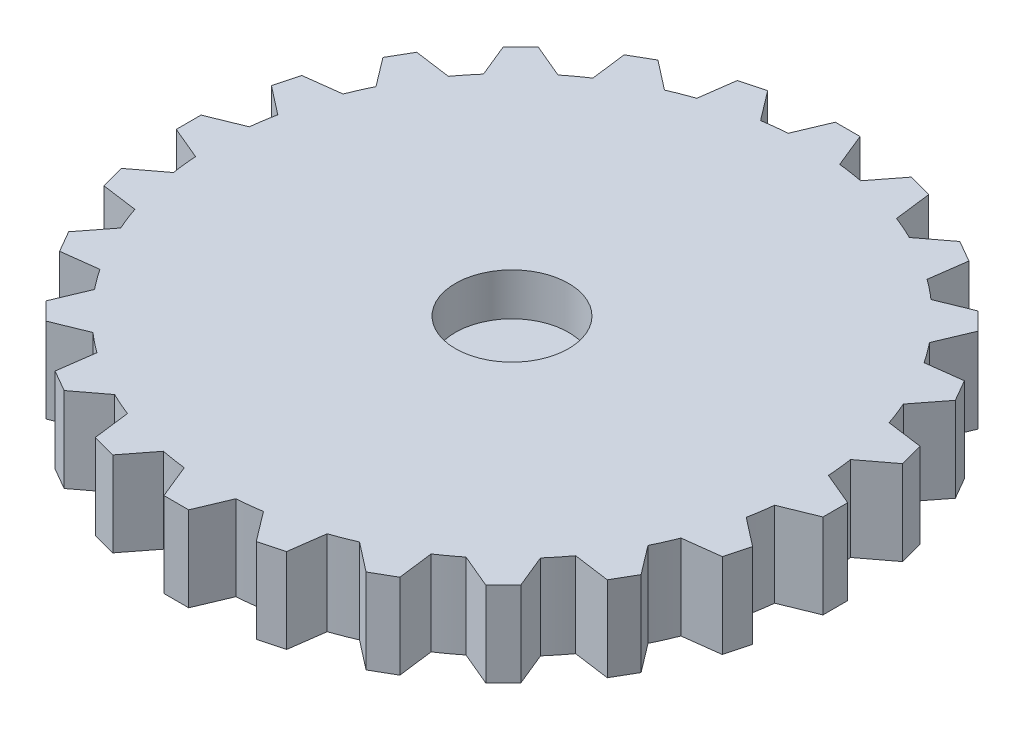
from build123d import *

# Parameters (mm, degrees)
BOSS_EXTRUDE5_DEPTH = 6
BOSS_EXTRUDE6_DEPTH = 3
SKETCH4_R           = 4
CUT_EXTRUDE1_DEPTH  = 10


with BuildPart() as part:
    # Sketch3 → Boss-Extrude5 (new body)
    with BuildSketch(Plane(origin=(0, 0, 0), x_dir=(1, 0, 0), z_dir=(0, 1, 0))):
        with BuildLine():
            Line((23.301465589, -1.311541929), (23.301465589, 0.438458071))
            Line((23.301465589, 0.438458071), (20.951465589, 1.426916143))
            ThreePointArc((20.951465589, 1.426916143), (20.873013262, 2.30593091), (20.757698449, 3.180873321))
            Line((20.757698449, 3.180873321), (22.846939432, 4.764010852))
            Line((22.846939432, 4.764010852), (22.394006103, 6.454381048))
            Line((22.394006103, 6.454381048), (19.868248637, 6.800933471))
            ThreePointArc((19.868248637, 6.800933471), (19.564963746, 7.629691581), (19.227126431, 8.444975382))
            Line((19.227126431, 8.444975382), (20.83543211, 10.514904166))
            Line((20.83543211, 10.514904166), (19.96043211, 12.030448623))
            Line((19.96043211, 12.030448623), (17.431043375, 11.711478423))
            ThreePointArc((17.431043375, 11.711478423), (16.923594283, 12.433501379), (16.386257521, 13.133566327))
            Line((16.386257521, 13.133566327), (17.404024521, 15.549224138))
            Line((17.404024521, 15.549224138), (16.166587654, 16.786661005))
            Line((16.166587654, 16.786661005), (13.805941313, 15.823905474))
            ThreePointArc((13.805941313, 15.823905474), (13.128909838, 16.389988605), (12.42869224, 16.927126431))
            Line((12.42869224, 16.927126431), (12.786561423, 19.523890181))
            Line((12.786561423, 19.523890181), (11.271016966, 20.398890181))
            Line((11.271016966, 20.398890181), (9.239987166, 18.857959518))
            ThreePointArc((9.239987166, 18.857959518), (8.439511883, 19.229525194), (7.624132122, 19.567130842))
            Line((7.624132122, 19.567130842), (7.297715294, 22.168035373))
            Line((7.297715294, 22.168035373), (5.607345098, 22.620968702))
            Line((5.607345098, 22.620968702), (4.044343163, 20.606874784))
            ThreePointArc((4.044343163, 20.606874784), (3.174975141, 20.758601419), (2.3, 20.873667622))
            Line((2.3, 20.873667622), (1.311541929, 23.301465589))
            Line((1.311541929, 23.301465589), (-0.438458071, 23.301465589))
            Line((-0.438458071, 23.301465589), (-1.426916143, 20.951465589))
            ThreePointArc((-1.426916143, 20.951465589), (-2.30593091, 20.873013262), (-3.180873321, 20.757698449))
            Line((-3.180873321, 20.757698449), (-4.764010852, 22.846939432))
            Line((-4.764010852, 22.846939432), (-6.454381048, 22.394006103))
            Line((-6.454381048, 22.394006103), (-6.800933471, 19.868248637))
            ThreePointArc((-6.800933471, 19.868248637), (-7.629691581, 19.564963746), (-8.444975382, 19.227126431))
            Line((-8.444975382, 19.227126431), (-10.514904166, 20.83543211))
            Line((-10.514904166, 20.83543211), (-12.030448623, 19.96043211))
            Line((-12.030448623, 19.96043211), (-11.711478423, 17.431043375))
            ThreePointArc((-11.711478423, 17.431043375), (-12.433501379, 16.923594283), (-13.133566327, 16.386257521))
            Line((-13.133566327, 16.386257521), (-15.549224138, 17.404024521))
            Line((-15.549224138, 17.404024521), (-16.786661005, 16.166587654))
            Line((-16.786661005, 16.166587654), (-15.823905474, 13.805941313))
            ThreePointArc((-15.823905474, 13.805941313), (-16.389988605, 13.128909838), (-16.927126431, 12.42869224))
            Line((-16.927126431, 12.42869224), (-19.523890181, 12.786561423))
            Line((-19.523890181, 12.786561423), (-20.398890181, 11.271016966))
            Line((-20.398890181, 11.271016966), (-18.857959518, 9.239987166))
            ThreePointArc((-18.857959518, 9.239987166), (-19.229525194, 8.439511883), (-19.567130842, 7.624132122))
            Line((-19.567130842, 7.624132122), (-22.168035373, 7.297715294))
            Line((-22.168035373, 7.297715294), (-22.620968702, 5.607345098))
            Line((-22.620968702, 5.607345098), (-20.606874784, 4.044343163))
            ThreePointArc((-20.606874784, 4.044343163), (-20.758601419, 3.174975141), (-20.873667622, 2.3))
            Line((-20.873667622, 2.3), (-23.301465589, 1.311541929))
            Line((-23.301465589, 1.311541929), (-23.301465589, -0.438458071))
            Line((-23.301465589, -0.438458071), (-20.951465589, -1.426916143))
            ThreePointArc((-20.951465589, -1.426916143), (-20.873013262, -2.30593091), (-20.757698449, -3.180873321))
            Line((-20.757698449, -3.180873321), (-22.846939432, -4.764010852))
            Line((-22.846939432, -4.764010852), (-22.394006103, -6.454381048))
            Line((-22.394006103, -6.454381048), (-19.868248637, -6.800933471))
            ThreePointArc((-19.868248637, -6.800933471), (-19.564963746, -7.629691581), (-19.227126431, -8.444975382))
            Line((-19.227126431, -8.444975382), (-20.83543211, -10.514904166))
            Line((-20.83543211, -10.514904166), (-19.96043211, -12.030448623))
            Line((-19.96043211, -12.030448623), (-17.431043375, -11.711478423))
            ThreePointArc((-17.431043375, -11.711478423), (-16.923594283, -12.433501379), (-16.386257521, -13.133566327))
            Line((-16.386257521, -13.133566327), (-17.404024521, -15.549224138))
            Line((-17.404024521, -15.549224138), (-16.166587654, -16.786661005))
            Line((-16.166587654, -16.786661005), (-13.805941313, -15.823905474))
            ThreePointArc((-13.805941313, -15.823905474), (-13.128909838, -16.389988605), (-12.42869224, -16.927126431))
            Line((-12.42869224, -16.927126431), (-12.786561423, -19.523890181))
            Line((-12.786561423, -19.523890181), (-11.271016966, -20.398890181))
            Line((-11.271016966, -20.398890181), (-9.239987166, -18.857959518))
            ThreePointArc((-9.239987166, -18.857959518), (-8.439511883, -19.229525194), (-7.624132122, -19.567130842))
            Line((-7.624132122, -19.567130842), (-7.297715294, -22.168035373))
            Line((-7.297715294, -22.168035373), (-5.607345098, -22.620968702))
            Line((-5.607345098, -22.620968702), (-4.044343163, -20.606874784))
            ThreePointArc((-4.044343163, -20.606874784), (-3.174975141, -20.758601419), (-2.3, -20.873667622))
            Line((-2.3, -20.873667622), (-1.311541929, -23.301465589))
            Line((-1.311541929, -23.301465589), (0.438458071, -23.301465589))
            Line((0.438458071, -23.301465589), (1.426916143, -20.951465589))
            ThreePointArc((1.426916143, -20.951465589), (2.30593091, -20.873013262), (3.180873321, -20.757698449))
            Line((3.180873321, -20.757698449), (4.764010852, -22.846939432))
            Line((4.764010852, -22.846939432), (6.454381048, -22.394006103))
            Line((6.454381048, -22.394006103), (6.800933471, -19.868248637))
            ThreePointArc((6.800933471, -19.868248637), (7.629691581, -19.564963746), (8.444975382, -19.227126431))
            Line((8.444975382, -19.227126431), (10.514904166, -20.83543211))
            Line((10.514904166, -20.83543211), (12.030448623, -19.96043211))
            Line((12.030448623, -19.96043211), (11.711478423, -17.431043375))
            ThreePointArc((11.711478423, -17.431043375), (12.433501379, -16.923594283), (13.133566327, -16.386257521))
            Line((13.133566327, -16.386257521), (15.549224138, -17.404024521))
            Line((15.549224138, -17.404024521), (16.786661005, -16.166587654))
            Line((16.786661005, -16.166587654), (15.823905474, -13.805941313))
            ThreePointArc((15.823905474, -13.805941313), (16.389988605, -13.128909838), (16.927126431, -12.42869224))
            Line((16.927126431, -12.42869224), (19.523890181, -12.786561423))
            Line((19.523890181, -12.786561423), (20.398890181, -11.271016966))
            Line((20.398890181, -11.271016966), (18.857959518, -9.239987166))
            ThreePointArc((18.857959518, -9.239987166), (19.229525194, -8.439511883), (19.567130842, -7.624132122))
            Line((19.567130842, -7.624132122), (22.168035373, -7.297715294))
            Line((22.168035373, -7.297715294), (22.620968702, -5.607345098))
            Line((22.620968702, -5.607345098), (20.606874784, -4.044343163))
            ThreePointArc((20.606874784, -4.044343163), (20.758601419, -3.174975141), (20.873667622, -2.3))
            Line((20.873667622, -2.3), (23.301465589, -1.311541929))
        make_face()
    extrude(amount=BOSS_EXTRUDE5_DEPTH)

    # Sketch4 → Cut-Extrude1 (cut)
    with BuildSketch(Plane(origin=(0, 6, 0), x_dir=(1, 0, 0), z_dir=(0, 1, 0))):
        Circle(SKETCH4_R)
    extrude(amount=-CUT_EXTRUDE1_DEPTH, mode=Mode.SUBTRACT)


with BuildPart() as body_2:
    # Sketch1 → Boss-Extrude6 (new body)
    with BuildSketch(Plane(origin=(0, 0, 0), x_dir=(1, 0, 0), z_dir=(0, 1, 0))):
        with BuildLine():
            Line((-0.5, 14.746169466), (0.5, 14.746169466))
            Line((0.5, 14.746169466), (2, 12.544128437))
            ThreePointArc((2, 12.544128437), (2.588190451, 12.405427729), (3.166928678, 12.23145084))
            Line((3.166928678, 12.23145084), (5.566987298, 13.388474311))
            Line((5.566987298, 13.388474311), (6.433012702, 12.888474311))
            Line((6.433012702, 12.888474311), (6.631030293, 10.23145084))
            ThreePointArc((6.631030293, 10.23145084), (7.071067812, 9.817237278), (7.485281374, 9.377199759))
            Line((7.485281374, 9.377199759), (10.142304845, 9.179182168))
            Line((10.142304845, 9.179182168), (10.642304845, 8.313156764))
            Line((10.642304845, 8.313156764), (9.485281374, 5.913098144))
            ThreePointArc((9.485281374, 5.913098144), (9.659258263, 5.334359917), (9.797958971, 4.746169466))
            Line((9.797958971, 4.746169466), (12, 3.246169466))
            Line((12, 3.246169466), (12, 2.246169466))
            Line((12, 2.246169466), (9.797958971, 0.746169466))
            ThreePointArc((9.797958971, 0.746169466), (9.659258263, 0.157979015), (9.485281374, -0.420759212))
            Line((9.485281374, -0.420759212), (10.642304845, -2.820817832))
            Line((10.642304845, -2.820817832), (10.142304845, -3.686843236))
            Line((10.142304845, -3.686843236), (7.485281374, -3.884860827))
            ThreePointArc((7.485281374, -3.884860827), (7.071067812, -4.324898346), (6.631030293, -4.739111908))
            Line((6.631030293, -4.739111908), (6.433012702, -7.39613538))
            Line((6.433012702, -7.39613538), (5.566987298, -7.89613538))
            Line((5.566987298, -7.89613538), (3.166928678, -6.739111908))
            ThreePointArc((3.166928678, -6.739111908), (2.588190451, -6.913088797), (2, -7.051789505))
            Line((2, -7.051789505), (0.5, -9.253830534))
            Line((0.5, -9.253830534), (-0.5, -9.253830534))
            Line((-0.5, -9.253830534), (-2, -7.051789505))
            ThreePointArc((-2, -7.051789505), (-2.588190451, -6.913088797), (-3.166928678, -6.739111908))
            Line((-3.166928678, -6.739111908), (-5.566987298, -7.89613538))
            Line((-5.566987298, -7.89613538), (-6.433012702, -7.39613538))
            Line((-6.433012702, -7.39613538), (-6.631030293, -4.739111908))
            ThreePointArc((-6.631030293, -4.739111908), (-7.071067812, -4.324898346), (-7.485281374, -3.884860827))
            Line((-7.485281374, -3.884860827), (-10.142304845, -3.686843236))
            Line((-10.142304845, -3.686843236), (-10.642304845, -2.820817832))
            Line((-10.642304845, -2.820817832), (-9.485281374, -0.420759212))
            ThreePointArc((-9.485281374, -0.420759212), (-9.659258263, 0.157979015), (-9.797958971, 0.746169466))
            Line((-9.797958971, 0.746169466), (-12, 2.246169466))
            Line((-12, 2.246169466), (-12, 3.246169466))
            Line((-12, 3.246169466), (-9.797958971, 4.746169466))
            ThreePointArc((-9.797958971, 4.746169466), (-9.659258263, 5.334359917), (-9.485281374, 5.913098144))
            Line((-9.485281374, 5.913098144), (-10.642304845, 8.313156764))
            Line((-10.642304845, 8.313156764), (-10.142304845, 9.179182168))
            Line((-10.142304845, 9.179182168), (-7.485281374, 9.377199759))
            ThreePointArc((-7.485281374, 9.377199759), (-7.071067812, 9.817237278), (-6.631030293, 10.23145084))
            Line((-6.631030293, 10.23145084), (-6.433012702, 12.888474311))
            Line((-6.433012702, 12.888474311), (-5.566987298, 13.388474311))
            Line((-5.566987298, 13.388474311), (-3.166928678, 12.23145084))
            ThreePointArc((-3.166928678, 12.23145084), (-2.588190451, 12.405427729), (-2, 12.544128437))
            Line((-2, 12.544128437), (-0.5, 14.746169466))
        make_face()
    extrude(amount=BOSS_EXTRUDE6_DEPTH)


solid = Compound([part.part, body_2.part])
